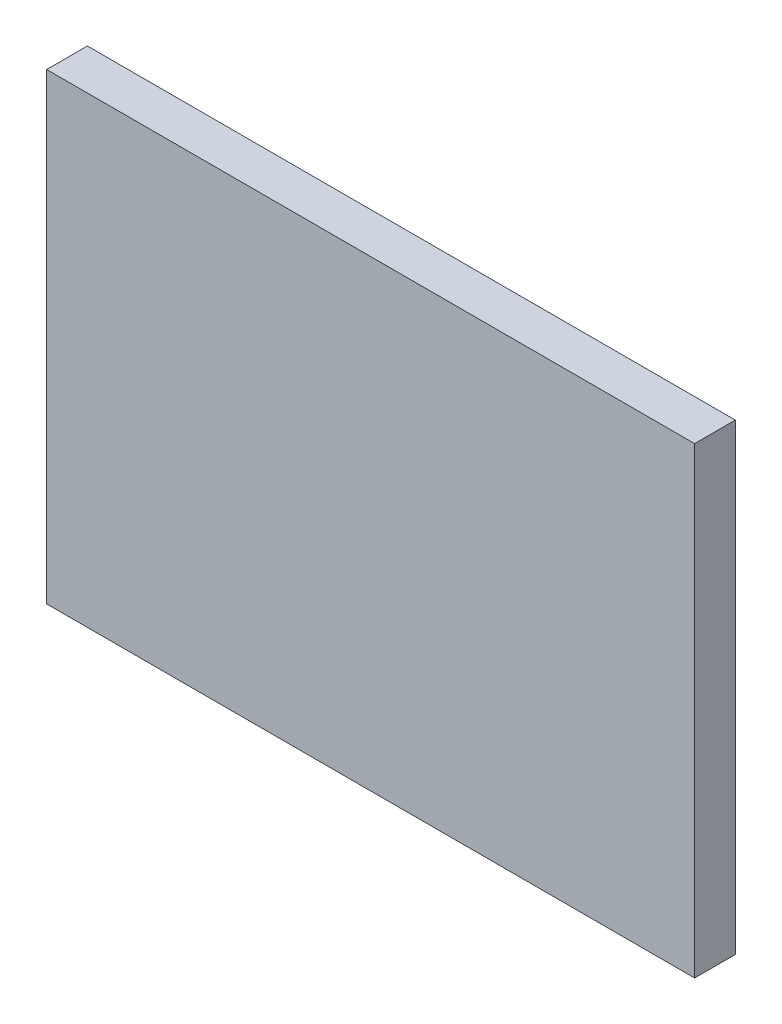
from build123d import *

# Parameters (mm, degrees)
SKETCH_1_W      = 17.5
SKETCH_1_H      = 12.5
EXTRUDE_1_DEPTH = 1.1


with BuildPart() as part:
    # 草图1 → 凸台-拉伸1 (new body)
    with BuildSketch(Plane.XY):
        Rectangle(SKETCH_1_W, SKETCH_1_H)
    extrude(amount=EXTRUDE_1_DEPTH)


solid = part.part
